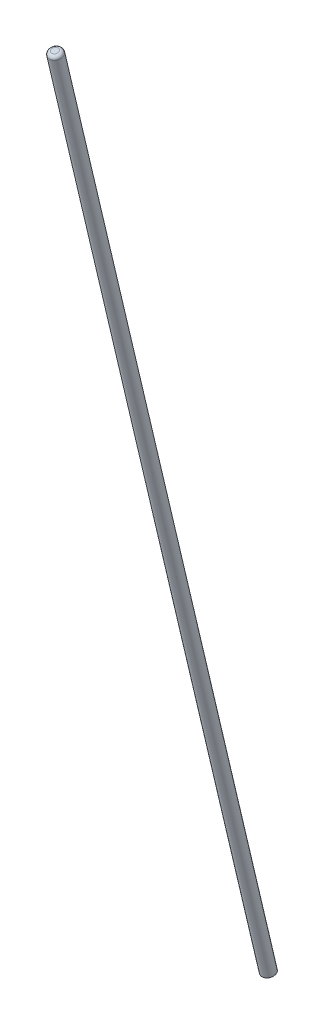
from build123d import *

# Parameters (mm, degrees)
SWEEP1_PROFILE_R = 5.08
FILLET1_R        = 2.54


with BuildPart() as part:
    # Sweep1: sweep along a curve in space
    with BuildLine() as sweep1_path:
        Line((1031.950801769, 1816.437106037, 948.53455637), (1037.030801769, 2531.816150146, 1121.25455637))
    # Sweep1 profile (on start of the path) → Sweep1 (sweep)
    with BuildSketch(Plane(origin=(1031.950801769, 1816.437106037, 948.53455637), x_dir=(0, -0.234694846, 0.972069097), z_dir=(0.006902625, 0.972045939, 0.234689255))):
        Circle(SWEEP1_PROFILE_R)
    sweep(path=sweep1_path.line)

    # Fillet1
    fillet1_edges = [part.edges().sort_by_distance(p)[0] for p in [
        (1037.030801769, 2533.008399963, 1116.316445357),
    ]]
    fillet(fillet1_edges, radius=FILLET1_R)


solid = part.part
